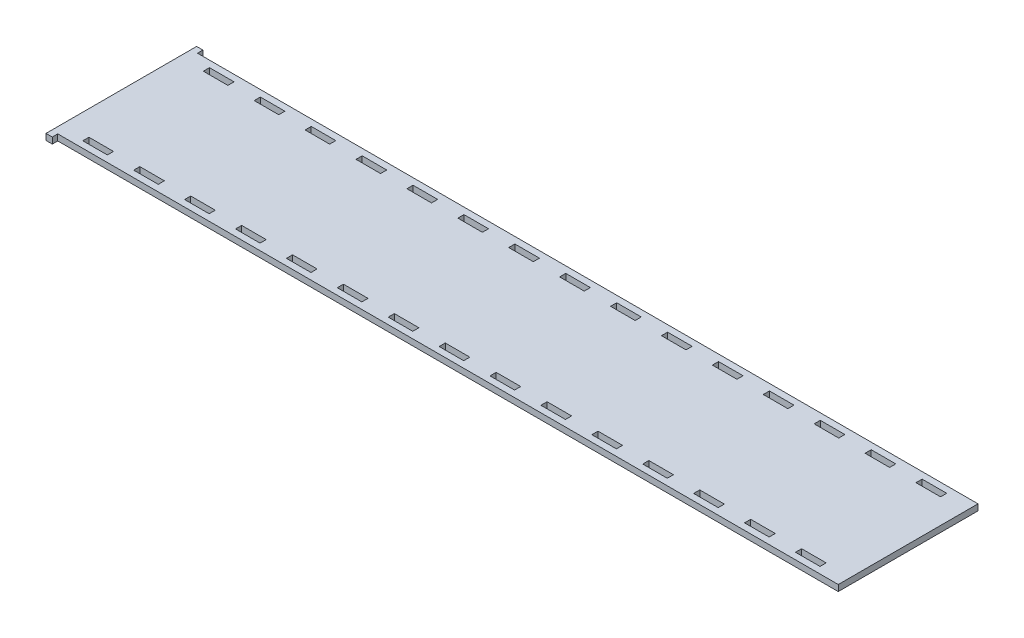
from build123d import *

# Parameters (mm, degrees)
SKETCH1_W           = 12.6968
SKETCH1_H           = 3.175
BOSS_EXTRUDE1_DEPTH = 3.175


with BuildPart() as part:
    # Sketch1 → Boss-Extrude1 (new body)
    with BuildSketch(Plane(origin=(0, 0, 0), x_dir=(1, 0, 0), z_dir=(0, 1, 0))):
        Polygon((-200.0487998, -36.1077), (203.3016, -36.1077), (203.3016, 36.1077), (-200.0487998, 36.1077), (-200.0487998, 38.9255), (-203.3016, 38.9255), (-203.3016, -38.9255), (-200.0487998, -38.9255), align=None)
        with Locations((-157.842857143, -31.142)):
            Rectangle(SKETCH1_W, SKETCH1_H, mode=Mode.SUBTRACT)
        with Locations((184.15, -31.142)):
            Rectangle(SKETCH1_W, SKETCH1_H, mode=Mode.SUBTRACT)
        with Locations((-131.535714286, -31.142)):
            Rectangle(SKETCH1_W, SKETCH1_H, mode=Mode.SUBTRACT)
        with Locations((-105.228571429, -31.142)):
            Rectangle(SKETCH1_W, SKETCH1_H, mode=Mode.SUBTRACT)
        with Locations((157.842857143, -31.142)):
            Rectangle(SKETCH1_W, SKETCH1_H, mode=Mode.SUBTRACT)
        with Locations((131.535714286, -31.142)):
            Rectangle(SKETCH1_W, SKETCH1_H, mode=Mode.SUBTRACT)
        with Locations((105.228571429, -31.142)):
            Rectangle(SKETCH1_W, SKETCH1_H, mode=Mode.SUBTRACT)
        with Locations((78.921428571, -31.142)):
            Rectangle(SKETCH1_W, SKETCH1_H, mode=Mode.SUBTRACT)
        with Locations((52.614285714, -31.142)):
            Rectangle(SKETCH1_W, SKETCH1_H, mode=Mode.SUBTRACT)
        with Locations((26.307142857, -31.142)):
            Rectangle(SKETCH1_W, SKETCH1_H, mode=Mode.SUBTRACT)
        with Locations((0, -31.142)):
            Rectangle(SKETCH1_W, SKETCH1_H, mode=Mode.SUBTRACT)
        with Locations((-26.307142857, -31.142)):
            Rectangle(SKETCH1_W, SKETCH1_H, mode=Mode.SUBTRACT)
        with Locations((-52.614285714, -31.142)):
            Rectangle(SKETCH1_W, SKETCH1_H, mode=Mode.SUBTRACT)
        with Locations((-78.921428571, -31.142)):
            Rectangle(SKETCH1_W, SKETCH1_H, mode=Mode.SUBTRACT)
        with Locations((-184.15, -31.142)):
            Rectangle(SKETCH1_W, SKETCH1_H, mode=Mode.SUBTRACT)
        with Locations((184.15, 31.142)):
            Rectangle(SKETCH1_W, SKETCH1_H, mode=Mode.SUBTRACT)
        with Locations((-157.842857143, 31.142)):
            Rectangle(SKETCH1_W, SKETCH1_H, mode=Mode.SUBTRACT)
        with Locations((-131.535714286, 31.142)):
            Rectangle(SKETCH1_W, SKETCH1_H, mode=Mode.SUBTRACT)
        with Locations((-105.228571429, 31.142)):
            Rectangle(SKETCH1_W, SKETCH1_H, mode=Mode.SUBTRACT)
        with Locations((-78.921428571, 31.142)):
            Rectangle(SKETCH1_W, SKETCH1_H, mode=Mode.SUBTRACT)
        with Locations((-52.614285714, 31.142)):
            Rectangle(SKETCH1_W, SKETCH1_H, mode=Mode.SUBTRACT)
        with Locations((-26.307142857, 31.142)):
            Rectangle(SKETCH1_W, SKETCH1_H, mode=Mode.SUBTRACT)
        with Locations((0, 31.142)):
            Rectangle(SKETCH1_W, SKETCH1_H, mode=Mode.SUBTRACT)
        with Locations((26.307142857, 31.142)):
            Rectangle(SKETCH1_W, SKETCH1_H, mode=Mode.SUBTRACT)
        with Locations((52.614285714, 31.142)):
            Rectangle(SKETCH1_W, SKETCH1_H, mode=Mode.SUBTRACT)
        with Locations((78.921428571, 31.142)):
            Rectangle(SKETCH1_W, SKETCH1_H, mode=Mode.SUBTRACT)
        with Locations((105.228571429, 31.142)):
            Rectangle(SKETCH1_W, SKETCH1_H, mode=Mode.SUBTRACT)
        with Locations((131.535714286, 31.142)):
            Rectangle(SKETCH1_W, SKETCH1_H, mode=Mode.SUBTRACT)
        with Locations((157.842857143, 31.142)):
            Rectangle(SKETCH1_W, SKETCH1_H, mode=Mode.SUBTRACT)
        with Locations((-184.15, 31.142)):
            Rectangle(SKETCH1_W, SKETCH1_H, mode=Mode.SUBTRACT)
    extrude(amount=BOSS_EXTRUDE1_DEPTH)


solid = part.part
